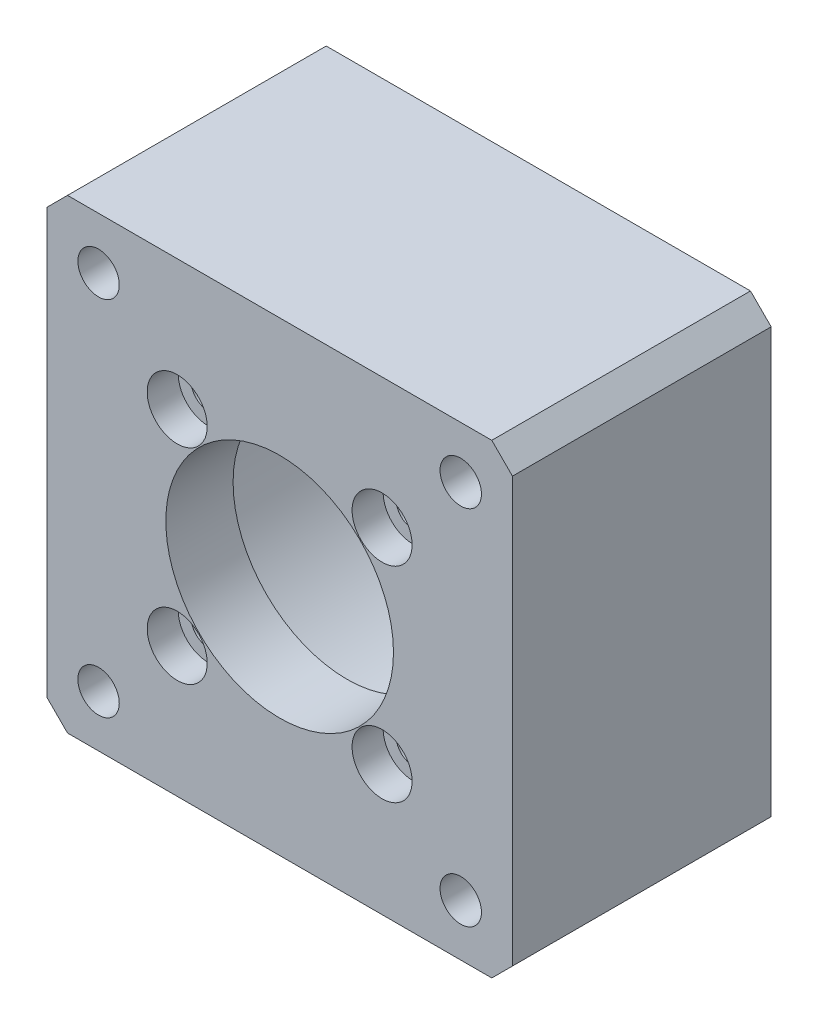
from build123d import *

# Parameters (mm, degrees)
SKETCH1_W            = 45
SKETCH1_H            = 45
SKETCH1_R            = 2
BOSS_EXTRUDE1_DEPTH  = 25
SKETCH2_R            = 1.65
SKETCH2_R_2          = 11
CUT_EXTRUDE1_DEPTH   = 25
SKETCH3_R            = 2.9
CUT_EXTRUDE2_DEPTH   = 3
CHAMFER1_SIZE        = 2
SKETCH4_R            = 18.15
CUT_EXTRUDE3_DEPTH   = 18.5
SKETCH_4_R           = 2
CUT_EXTRUDE_10_DEPTH = 4


with BuildPart() as part:
    # Sketch1 → Boss-Extrude1 (new body)
    with BuildSketch(Plane.XY):
        Rectangle(SKETCH1_W, SKETCH1_H)
        with Locations((-17.5, 17.5)):
            Circle(SKETCH1_R, mode=Mode.SUBTRACT)
        with Locations((17.5, 17.5)):
            Circle(SKETCH1_R, mode=Mode.SUBTRACT)
        with Locations((17.5, -17.5)):
            Circle(SKETCH1_R, mode=Mode.SUBTRACT)
        with Locations((-17.5, -17.5)):
            Circle(SKETCH1_R, mode=Mode.SUBTRACT)
    extrude(amount=BOSS_EXTRUDE1_DEPTH)

    # Sketch2 → Cut-Extrude1 (cut)
    with BuildSketch(Plane.XY.offset(25)):
        with Locations((9.899494937, 9.899494937)):
            Circle(SKETCH2_R)
        with Locations((9.899494937, -9.899494937)):
            Circle(SKETCH2_R)
        with Locations((-9.899494937, -9.899494937)):
            Circle(SKETCH2_R)
        with Locations((-9.899494937, 9.899494937)):
            Circle(SKETCH2_R)
        Circle(SKETCH2_R_2)
    extrude(amount=-CUT_EXTRUDE1_DEPTH, mode=Mode.SUBTRACT)

    # Sketch3 → Cut-Extrude2 (cut)
    with BuildSketch(Plane.XY.offset(25)):
        with Locations((9.899494937, 9.899494937)):
            Circle(SKETCH3_R)
        with Locations((9.899494937, -9.899494937)):
            Circle(SKETCH3_R)
        with Locations((-9.899494937, -9.899494937)):
            Circle(SKETCH3_R)
        with Locations((-9.899494937, 9.899494937)):
            Circle(SKETCH3_R)
    extrude(amount=-CUT_EXTRUDE2_DEPTH, mode=Mode.SUBTRACT)

    # Chamfer1
    chamfer1_edges = [part.edges().sort_by_distance(p)[0] for p in [
        (22.5, -22.5, 12.5),
        (-22.5, -22.5, 12.5),
        (-22.5, 22.5, 12.5),
        (22.5, 22.5, 12.5),
    ]]
    chamfer(chamfer1_edges, length=CHAMFER1_SIZE)

    # Sketch4 → Cut-Extrude3 (cut)
    with BuildSketch(Plane(origin=(0, 0, 0), x_dir=(-1, 0, 0), z_dir=(0, 0, -1))):
        Circle(SKETCH4_R)
    extrude(amount=-CUT_EXTRUDE3_DEPTH, mode=Mode.SUBTRACT)

    # 草图4 → 切除-拉伸10 (cut)
    with BuildSketch(Plane(origin=(0, 0, 0), x_dir=(-1, 0, 0), z_dir=(0, 0, -1))):
        Polygon((13.9, 19.578460969), (13.9, 15.421539031), (17.5, 13.343078062), (21.1, 15.421539031), (21.1, 19.578460969), (17.5, 21.656921938), align=None)
        with Locations((17.5, 17.5)):
            Circle(SKETCH_4_R, mode=Mode.SUBTRACT)
        Polygon((-21.1, 19.578460969), (-21.1, 15.421539031), (-17.5, 13.343078062), (-13.9, 15.421539031), (-13.9, 19.578460969), (-17.5, 21.656921938), align=None)
        with Locations((-17.5, 17.5)):
            Circle(SKETCH_4_R, mode=Mode.SUBTRACT)
        Polygon((-21.1, -15.421539031), (-21.1, -19.578460969), (-17.5, -21.656921938), (-13.9, -19.578460969), (-13.9, -15.421539031), (-17.5, -13.343078062), align=None)
        with Locations((-17.5, -17.5)):
            Circle(SKETCH_4_R, mode=Mode.SUBTRACT)
        Polygon((13.9, -15.421539031), (13.9, -19.578460969), (17.5, -21.656921938), (21.1, -19.578460969), (21.1, -15.421539031), (17.5, -13.343078062), align=None)
        with Locations((17.5, -17.5)):
            Circle(SKETCH_4_R, mode=Mode.SUBTRACT)
    extrude(amount=-CUT_EXTRUDE_10_DEPTH, mode=Mode.SUBTRACT)


solid = part.part
